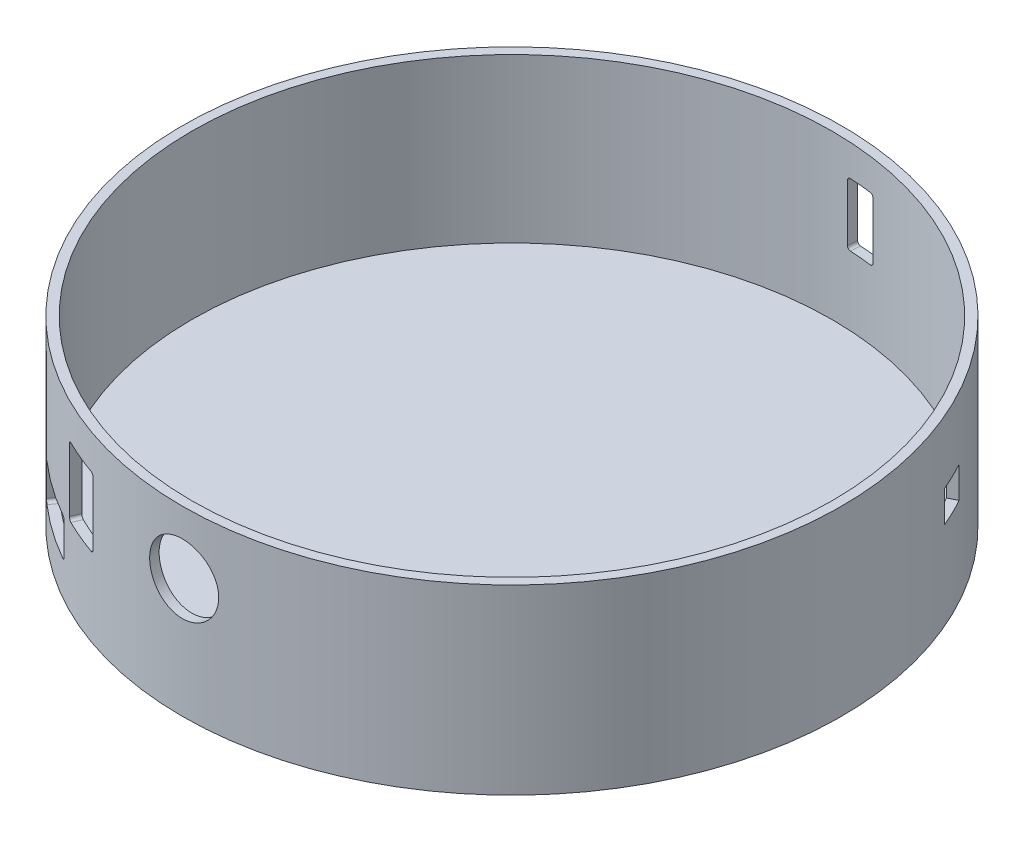
from build123d import *

# Parameters (mm, degrees)
P_IDAT_VYSUNUT_M1_DEPTH      = 26
P_IDAT_VYSUNUT_M1_DEPTH_BACK = 3
SKICA1_R                     = 52.5
SKICA1_R_2                   = 51
SKICA1_3_R                   = 51
P_IDAT_VYSUNUT_M3_DEPTH      = 3
ODEBRAT_START                = 2.5
ODEBRAT_VYSUNUT_M1_DEPTH     = 6
ODEBRAT_START_2              = 9.5
ODEBRAT_VYSUNUT_M2_DEPTH     = 11
ZAOBLIT1_R                   = 0.5
ZAOBLIT2_R                   = 0.5
ODEBRAT_START_3              = 11
ODEBRAT_VYSUNUT_M3_DEPTH     = 10
ZAOBLIT3_R                   = 0.5
SKICA6_W                     = 5.5
SKICA6_H                     = 2.5
ODEBRAT_VYSUNUT_M4_DEPTH     = 5


with BuildPart() as part:
    # Skica1 → P_idat vysunut_m1 (new, two sides: drawn at the far end of the back side and taken through both)
    with BuildSketch(Plane(origin=(0, 0, 0), x_dir=(1, 0, 0), z_dir=(0, 1, 0)).offset(-P_IDAT_VYSUNUT_M1_DEPTH_BACK)):
        Circle(SKICA1_R)
        Circle(SKICA1_R_2, mode=Mode.SUBTRACT)
    extrude(amount=P_IDAT_VYSUNUT_M1_DEPTH + P_IDAT_VYSUNUT_M1_DEPTH_BACK)

    # Skica1_3 → P_idat vysunut_m3 (add)
    with BuildSketch(Plane(origin=(0, 0, 0), x_dir=(1, 0, 0), z_dir=(0, 1, 0))):
        Circle(SKICA1_3_R)
    extrude(amount=-P_IDAT_VYSUNUT_M3_DEPTH)

    # Skica3 → Odebrat vysunut_m1 (cut)
    with BuildSketch(Plane(origin=(0, 0, 0), x_dir=(1, 0, 0), z_dir=(0, 1, 0)).offset(ODEBRAT_START)):
        Polygon((-24.5, -44.729744019), (-25.943243016, -46.771079267), (-35.443243016, -40.054490866), (-34, -38.013155617), align=None)
    extrude(amount=ODEBRAT_VYSUNUT_M1_DEPTH, mode=Mode.SUBTRACT)

    # Skica4 → Odebrat vysunut_m2 (cut)
    with BuildSketch(Plane(origin=(0, 0, 0), x_dir=(1, 0, 0), z_dir=(0, 1, 0)).offset(ODEBRAT_START_2)):
        Polygon((-16.5, -48.257123826), (-17.470460132, -50.561078499), (-23.970460132, -47.823181379), (-23, -45.519226707), align=None)
    extrude(amount=ODEBRAT_VYSUNUT_M2_DEPTH, mode=Mode.SUBTRACT)

    # Zaoblit1
    zaoblit1_edges = [part.edges().sort_by_distance(p)[0] for p in [
        (-34.435735274, 8.5, 38.629463311),
        (-24.935735274, 8.5, 45.346051713),
        (-24.935735274, 2.5, 45.346051713),
        (-34.435735274, 2.5, 38.629463311),
    ]]
    fillet(zaoblit1_edges, radius=ZAOBLIT1_R)

    # Zaoblit2
    zaoblit2_edges = [part.edges().sort_by_distance(p)[0] for p in [
        (-16.791816548, 9.5, 48.949921063),
        (-16.791816548, 20.5, 48.949921063),
        (-23.291816548, 20.5, 46.212023944),
        (-23.291816548, 9.5, 46.212023944),
    ]]
    fillet(zaoblit2_edges, radius=ZAOBLIT2_R)

    # Skica5 → Odebrat vysunut_m3 (cut)
    with BuildSketch(Plane(origin=(0, 0, 0), x_dir=(1, 0, 0), z_dir=(0, 1, 0)).offset(ODEBRAT_START_3)):
        Polygon((2.5, 50.938688636), (2.734091597, 53.438688636), (7.234091597, 53.017323761), (7, 50.517323761), align=None)
    extrude(amount=ODEBRAT_VYSUNUT_M3_DEPTH, mode=Mode.SUBTRACT)

    # Zaoblit3
    zaoblit3_edges = [part.edges().sort_by_distance(p)[0] for p in [
        (7.069988396, 21, -51.264770449),
        (2.569988396, 21, -51.686135324),
        (2.569988396, 11, -51.686135324),
        (7.069988396, 11, -51.264770449),
    ]]
    fillet(zaoblit3_edges, radius=ZAOBLIT3_R)

    # Skica6 → Odebrat rotac_1 (revolve, cut)
    with BuildSketch(Plane(origin=(0, 16, 0), x_dir=(1, 0, 0), z_dir=(0, 1, 0))):
        with Locations((-2.75, -51.25)):
            Rectangle(SKICA6_W, SKICA6_H)
    revolve(axis=Axis((0, 16, -58.211377778), (0, 0, 1)), mode=Mode.SUBTRACT)

    # Skica7 → Odebrat vysunut_m4 (cut)
    with BuildSketch(Plane(origin=(0, 16, 0), x_dir=(1, 0, 0), z_dir=(0, 1, 0))):
        Polygon((46.914816423, 20), (44.730924047, 24.497845494), (46.979846795, 25.589791682), (49.16373917, 21.091946188), align=None)
    extrude(amount=-ODEBRAT_VYSUNUT_M4_DEPTH, mode=Mode.SUBTRACT)


solid = part.part
